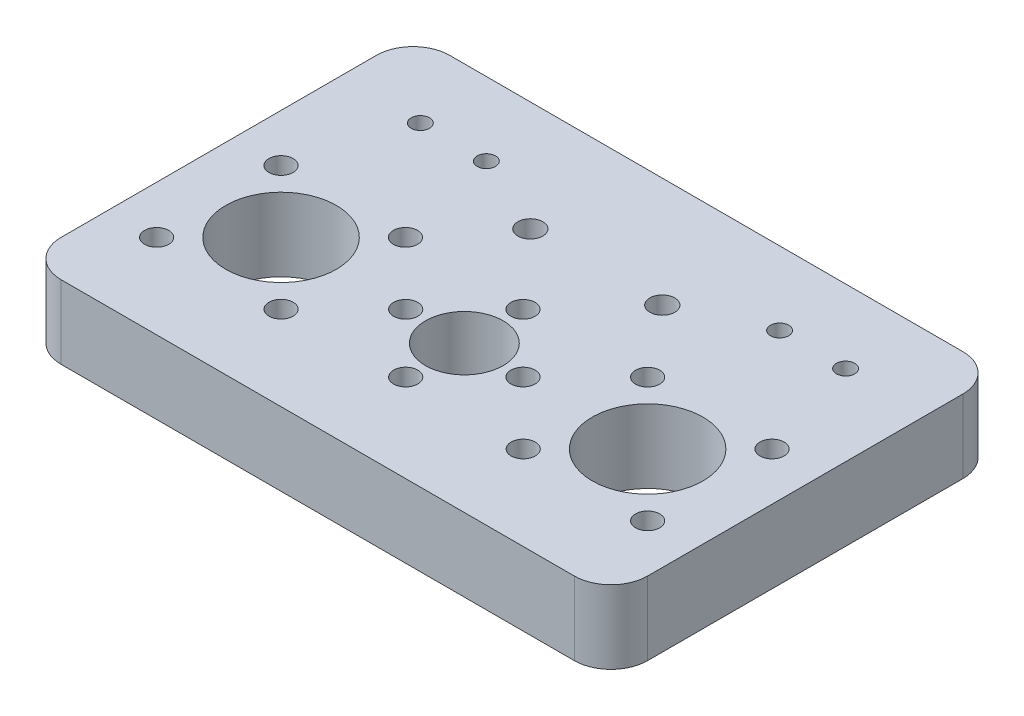
from build123d import *

# Parameters (mm, degrees)
SKETCH_1_R          = 5.3
SKETCH_1_R_2        = 1.65
SKETCH_1_R_3        = 7.55
SKETCH_1_R_4        = 1.25
EXTRUDE_1_DEPTH     = 10
SKETCH_2_R          = 1.7
CUT_EXTRUDE_1_DEPTH = 10


with BuildPart() as part:
    # 草图1 → 凸台-拉伸1 (new body)
    with BuildSketch(Plane(origin=(0, 0, 0), x_dir=(1, 0, 0), z_dir=(0, 1, 0))):
        with BuildLine():
            Line((-35, 33), (35, 33))
            ThreePointArc((35, 33), (38.535533906, 31.535533906), (40, 28))
            Line((40, 28), (40, -15))
            ThreePointArc((40, -15), (38.535533906, -18.535533906), (35, -20))
            Line((35, -20), (-35, -20))
            ThreePointArc((-35, -20), (-38.535533906, -18.535533906), (-40, -15))
            Line((-40, -15), (-40, 28))
            ThreePointArc((-40, 28), (-38.535533906, 31.535533906), (-35, 33))
        make_face()
        Circle(SKETCH_1_R, mode=Mode.SUBTRACT)
        with Locations((0, 8)):
            Circle(SKETCH_1_R_2, mode=Mode.SUBTRACT)
        with Locations((8, 0)):
            Circle(SKETCH_1_R_2, mode=Mode.SUBTRACT)
        with Locations((0, -8)):
            Circle(SKETCH_1_R_2, mode=Mode.SUBTRACT)
        with Locations((-8, 0)):
            Circle(SKETCH_1_R_2, mode=Mode.SUBTRACT)
        with Locations((-25, 0)):
            Circle(SKETCH_1_R_3, mode=Mode.SUBTRACT)
        with Locations((-33.485281374, 8.485281374)):
            Circle(SKETCH_1_R_2, mode=Mode.SUBTRACT)
        with Locations((-16.514718626, 8.485281374)):
            Circle(SKETCH_1_R_2, mode=Mode.SUBTRACT)
        with Locations((-16.514718626, -8.485281374)):
            Circle(SKETCH_1_R_2, mode=Mode.SUBTRACT)
        with Locations((-33.485281374, -8.485281374)):
            Circle(SKETCH_1_R_2, mode=Mode.SUBTRACT)
        with Locations((25, 0)):
            Circle(SKETCH_1_R_3, mode=Mode.SUBTRACT)
        with Locations((16.514718626, 8.485281374)):
            Circle(SKETCH_1_R_2, mode=Mode.SUBTRACT)
        with Locations((16.514718626, -8.485281374)):
            Circle(SKETCH_1_R_2, mode=Mode.SUBTRACT)
        with Locations((33.485281374, -8.485281374)):
            Circle(SKETCH_1_R_2, mode=Mode.SUBTRACT)
        with Locations((33.485281374, 8.485281374)):
            Circle(SKETCH_1_R_2, mode=Mode.SUBTRACT)
        with Locations((-20, 23)):
            Circle(SKETCH_1_R_4, mode=Mode.SUBTRACT)
        with Locations((20, 23)):
            Circle(SKETCH_1_R_4, mode=Mode.SUBTRACT)
        with Locations((-29, 23)):
            Circle(SKETCH_1_R_4, mode=Mode.SUBTRACT)
        with Locations((29, 23)):
            Circle(SKETCH_1_R_4, mode=Mode.SUBTRACT)
    extrude(amount=EXTRUDE_1_DEPTH)

    # 草图2 → 切除-拉伸1 (cut)
    with BuildSketch(Plane(origin=(0, 10, 0), x_dir=(1, 0, 0), z_dir=(0, 1, 0))):
        with Locations((-9, 18)):
            Circle(SKETCH_2_R)
        with Locations((9, 18)):
            Circle(SKETCH_2_R)
    extrude(amount=-CUT_EXTRUDE_1_DEPTH, mode=Mode.SUBTRACT)


solid = part.part
